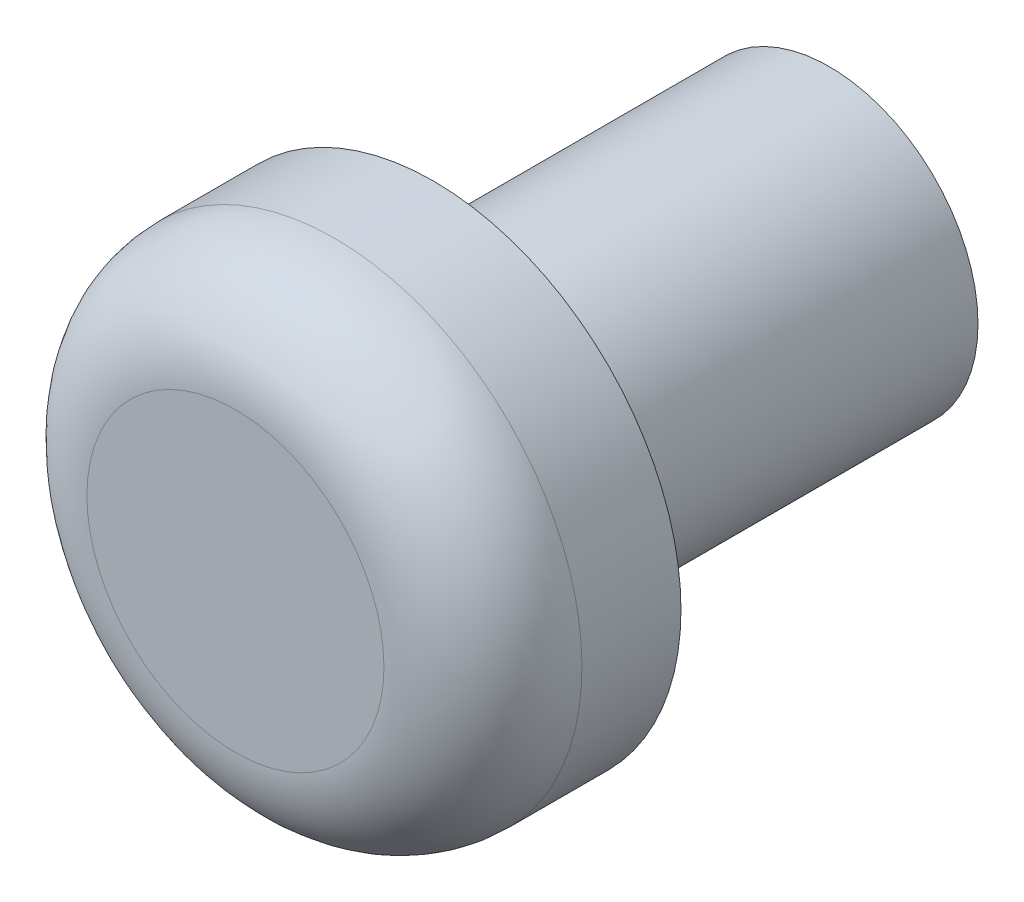
from build123d import *

# Parameters (mm, degrees)
SKETCH1_R           = 2.5
BOSS_EXTRUDE1_DEPTH = 2
SKETCH2_R           = 1.5
BOSS_EXTRUDE2_DEPTH = 4
FILLET2_R           = 1
SKETCH3_R           = 0.5
CUT_EXTRUDE1_DEPTH  = 2


with BuildPart() as part:
    # Sketch1 → Boss-Extrude1 (new body)
    with BuildSketch(Plane.XY):
        Circle(SKETCH1_R)
    extrude(amount=-BOSS_EXTRUDE1_DEPTH)

    # Sketch2 → Boss-Extrude2 (add)
    with BuildSketch(Plane(origin=(0, 0, -2), x_dir=(-1, 0, 0), z_dir=(0, 0, -1))):
        Circle(SKETCH2_R)
    extrude(amount=BOSS_EXTRUDE2_DEPTH)

    # Fillet2
    fillet2_edges = [part.edges().sort_by_distance(p)[0] for p in [
        (-2.5, 0, 0),
    ]]
    fillet(fillet2_edges, radius=FILLET2_R)

    # Sketch3 → Cut-Extrude1 (cut)
    with BuildSketch(Plane(origin=(0, 0, -6), x_dir=(-1, 0, 0), z_dir=(0, 0, -1))):
        Circle(SKETCH3_R)
    extrude(amount=-CUT_EXTRUDE1_DEPTH, mode=Mode.SUBTRACT)


solid = part.part
